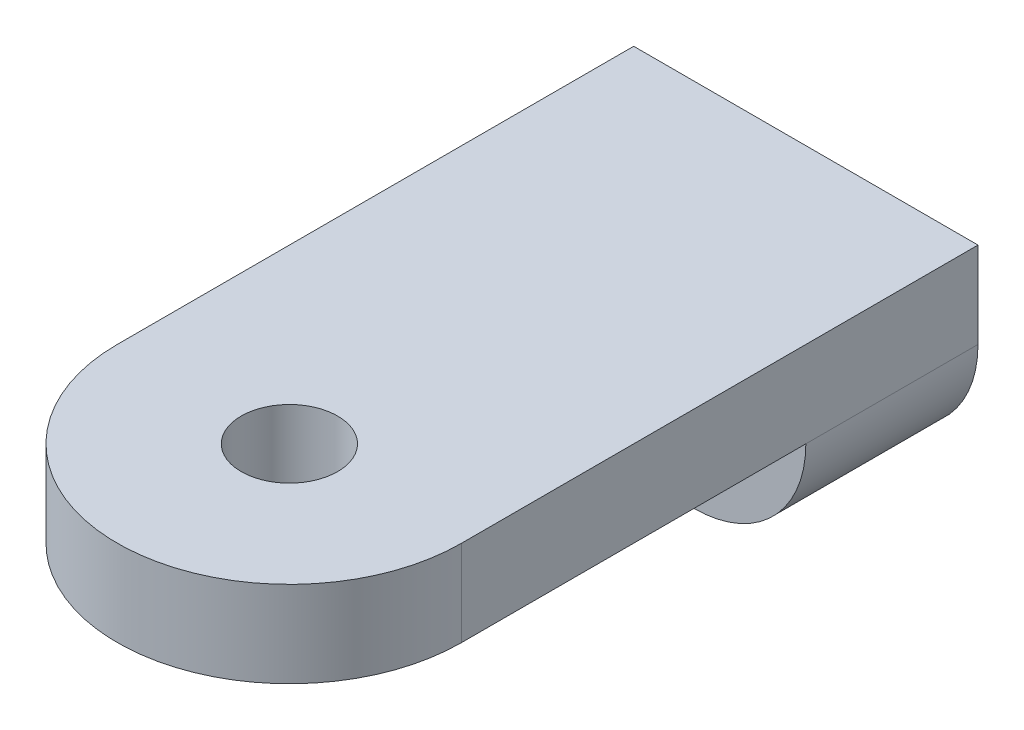
from build123d import *

# Parameters (mm, degrees)
SKETCH1_R           = 3.556
BOSS_EXTRUDE2_DEPTH = 6.35
SKETCH2_W           = 25.4
SKETCH2_H           = 12.7
BOSS_EXTRUDE3_DEPTH = 8.255
SKETCH3_W           = 1.27
SKETCH3_H           = 3.175
CUT_EXTRUDE1_DEPTH  = 3.175
SKETCH4_R           = 6.477
CUT_EXTRUDE2_DEPTH  = 6.604
FILLET1_R           = 8.255


with BuildPart() as part:
    # Sketch1 → Boss-Extrude2 (new body)
    with BuildSketch(Plane(origin=(0, 0, 0), x_dir=(1, 0, 0), z_dir=(0, 1, 0))):
        with BuildLine():
            Line((-12.7, 0), (-12.7, 38.1))
            Line((-12.7, 38.1), (12.7, 38.1))
            Line((12.7, 38.1), (12.7, 0))
            ThreePointArc((12.7, 0), (0, -12.7), (-12.7, 0))
        make_face()
        Circle(SKETCH1_R, mode=Mode.SUBTRACT)
    extrude(amount=BOSS_EXTRUDE2_DEPTH)

    # Sketch2 → Boss-Extrude3 (add)
    with BuildSketch(Plane.XZ):
        with Locations((0, -31.75)):
            Rectangle(SKETCH2_W, SKETCH2_H)
    extrude(amount=BOSS_EXTRUDE3_DEPTH)

    # Sketch3 → Cut-Extrude1 (cut)
    with BuildSketch(Plane.XY.offset(-25.4)):
        with Locations((0, -4.7625)):
            Rectangle(SKETCH3_W, SKETCH3_H)
    extrude(amount=-CUT_EXTRUDE1_DEPTH, mode=Mode.SUBTRACT)

    # Sketch4 → Cut-Extrude2 (cut)
    with BuildSketch(Plane(origin=(0, 0, -38.1), x_dir=(-1, 0, 0), z_dir=(0, 0, -1))):
        with Locations((0, -0.9525)):
            Circle(SKETCH4_R)
    extrude(amount=-CUT_EXTRUDE2_DEPTH, mode=Mode.SUBTRACT)

    # Fillet1
    fillet1_edges = [part.edges().sort_by_distance(p)[0] for p in [
        (-12.7, -8.255, -31.75),
        (12.7, -8.255, -31.75),
    ]]
    fillet(fillet1_edges, radius=FILLET1_R)


solid = part.part
